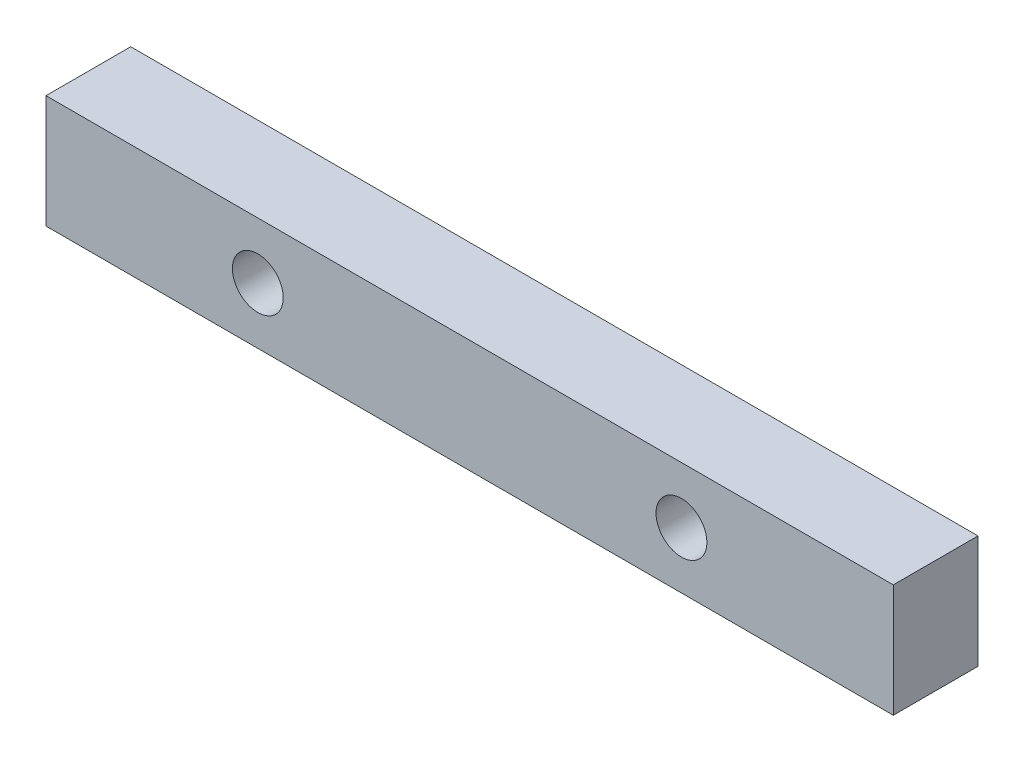
from build123d import *

# Parameters (mm, degrees)
SKETCH1_W                     = 150
SKETCH1_H                     = 20
BOSS_EXTRUDE1_DEPTH           = 15
CSK_FOR_M8_SFHCS1_D           = 9
CSK_FOR_M8_SFHCS1_CSINK_D     = 17.92
CSK_FOR_M8_SFHCS1_CSINK_ANGLE = 90


with BuildPart() as part:
    # Sketch1 → Boss-Extrude1 (new body)
    with BuildSketch(Plane.XY):
        Rectangle(SKETCH1_W, SKETCH1_H)
    extrude(amount=BOSS_EXTRUDE1_DEPTH)

    # CSK for M8 SFHCS1 (through all)
    with Locations(Plane(origin=(0, 0, 0), x_dir=(-1, 0, 0), z_dir=(0, 0, -1))):
        with Locations((-37.5, 0), (37.5, 0)):
            CounterSinkHole(CSK_FOR_M8_SFHCS1_D / 2, CSK_FOR_M8_SFHCS1_CSINK_D / 2, counter_sink_angle=CSK_FOR_M8_SFHCS1_CSINK_ANGLE)


solid = part.part
